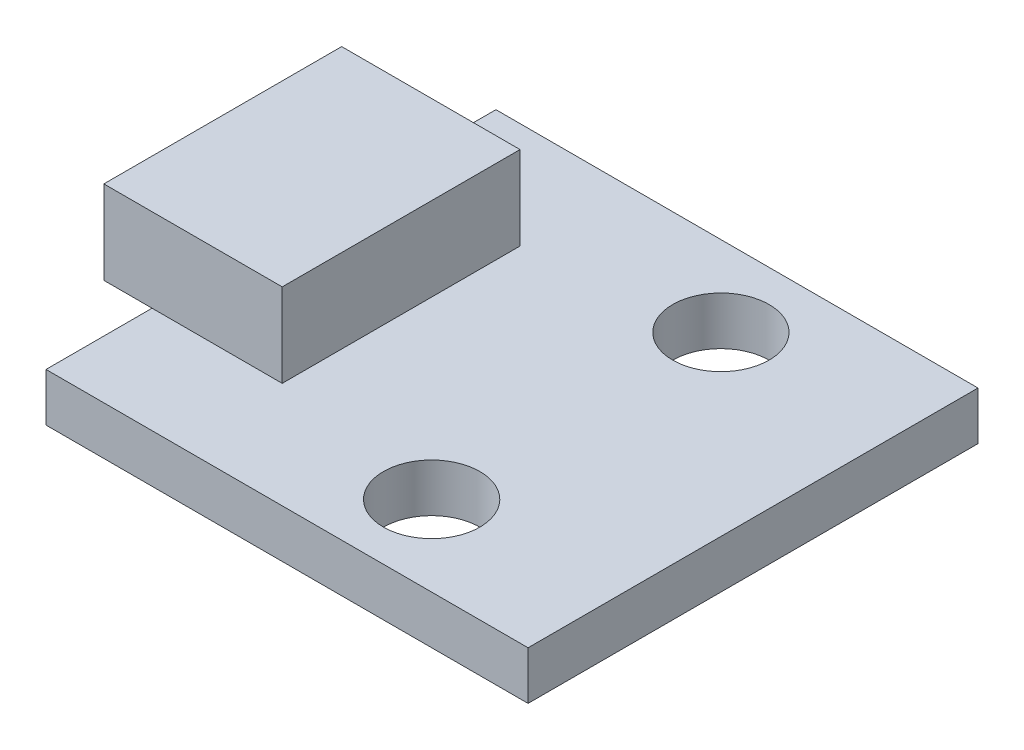
from build123d import *

# Parameters (mm, degrees)
SKETCH_1_W      = 3
SKETCH_1_H      = 14
SKETCH_1_W_2    = 4.05
SKETCH_1_H_2    = 7.4
EXTRUDE_1_DEPTH = 1.5
EXTRUDE_START   = 1.5
SKETCH_1_3_W    = 5.55
SKETCH_1_3_H    = 7.4
EXTRUDE_2_DEPTH = 2.6


with BuildPart() as part:
    # Эскиз1 → Бобышка-Вытянуть1 (new body)
    with BuildSketch(Plane(origin=(0, 0, 0), x_dir=(1, 0, 0), z_dir=(0, 1, 0))):
        with BuildLine():
            Line((4.5, 7), (2, 7))
            Line((2, 7), (2, 6))
            ThreePointArc((2, 6), (3.060660172, 5.560660172), (3.5, 4.5))
            ThreePointArc((3.5, 4.5), (3.060660172, 3.439339828), (2, 3))
            Line((2, 3), (2, -3))
            ThreePointArc((2, -3), (3.060660172, -3.439339828), (3.5, -4.5))
            ThreePointArc((3.5, -4.5), (3.060660172, -5.560660172), (2, -6))
            Line((2, -6), (2, -7))
            Line((2, -7), (4.5, -7))
            Line((4.5, -7), (4.5, 7))
        make_face()
        with Locations((6, 0)):
            Rectangle(SKETCH_1_W, SKETCH_1_H)
        with BuildLine():
            Line((-7.5, 7), (-7.5, 3.7))
            Line((-7.5, 3.7), (-3.45, 3.7))
            Line((-3.45, 3.7), (-3.45, -3.7))
            Line((-3.45, -3.7), (-7.5, -3.7))
            Line((-7.5, -3.7), (-7.5, -7))
            Line((-7.5, -7), (2, -7))
            Line((2, -7), (2, -6))
            ThreePointArc((2, -6), (0.5, -4.5), (2, -3))
            Line((2, -3), (2, 3))
            ThreePointArc((2, 3), (0.5, 4.5), (2, 6))
            Line((2, 6), (2, 7))
            Line((2, 7), (-7.5, 7))
        make_face()
        with Locations((-5.475, 0)):
            Rectangle(SKETCH_1_W_2, SKETCH_1_H_2)
    extrude(amount=EXTRUDE_1_DEPTH)

    # Эскиз1<3> → Бобышка-Вытянуть2 (add)
    with BuildSketch(Plane(origin=(0, 0, 0), x_dir=(1, 0, 0), z_dir=(0, 1, 0)).offset(EXTRUDE_START)):
        with Locations((-6.225, 0)):
            Rectangle(SKETCH_1_3_W, SKETCH_1_3_H)
    extrude(amount=EXTRUDE_2_DEPTH)


solid = part.part
